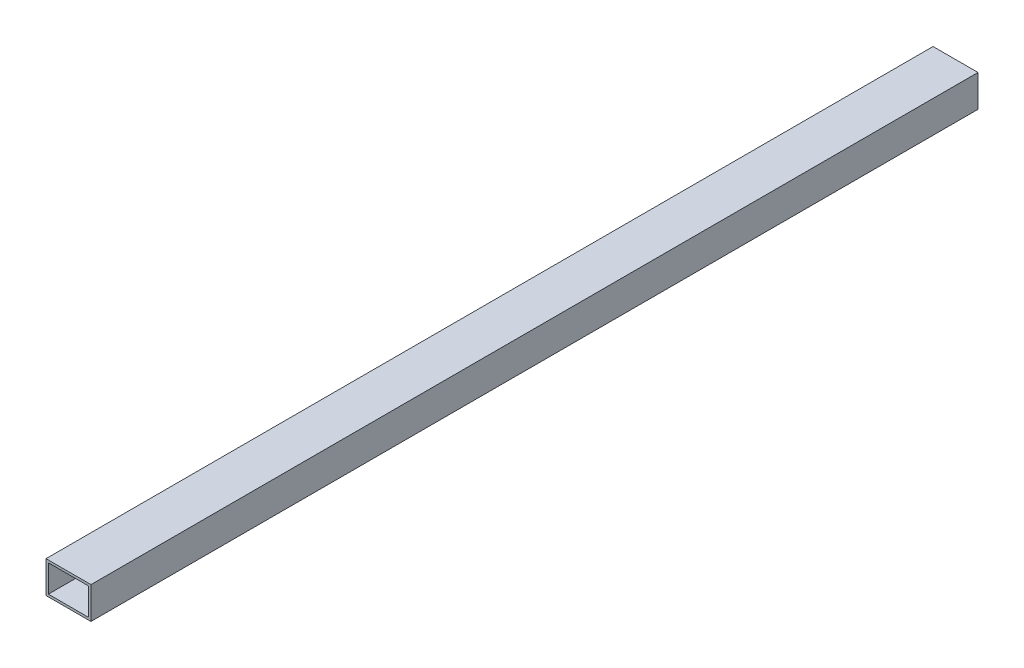
from build123d import *

# Parameters (mm, degrees)
SKETCH1_W           = 38
SKETCH1_H           = 27
SKETCH1_W_2         = 34
SKETCH1_H_2         = 23
BOSS_EXTRUDE1_DEPTH = 750


with BuildPart() as part:
    # Sketch1 → Boss-Extrude1 (new body)
    with BuildSketch(Plane.XY):
        Rectangle(SKETCH1_W, SKETCH1_H)
        Rectangle(SKETCH1_W_2, SKETCH1_H_2, mode=Mode.SUBTRACT)
    extrude(amount=BOSS_EXTRUDE1_DEPTH)


solid = part.part
